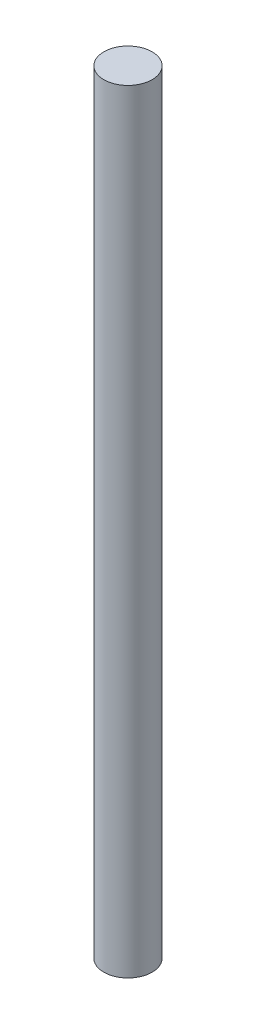
from build123d import *

# Parameters (mm, degrees)
SKETCH1_R           = 6.35
BOSS_EXTRUDE1_DEPTH = 203.2


with BuildPart() as part:
    # Sketch1 → Boss-Extrude1 (new body)
    with BuildSketch(Plane(origin=(0, 0, 0), x_dir=(1, 0, 0), z_dir=(0, 1, 0))):
        Circle(SKETCH1_R)
    extrude(amount=BOSS_EXTRUDE1_DEPTH)


solid = part.part
